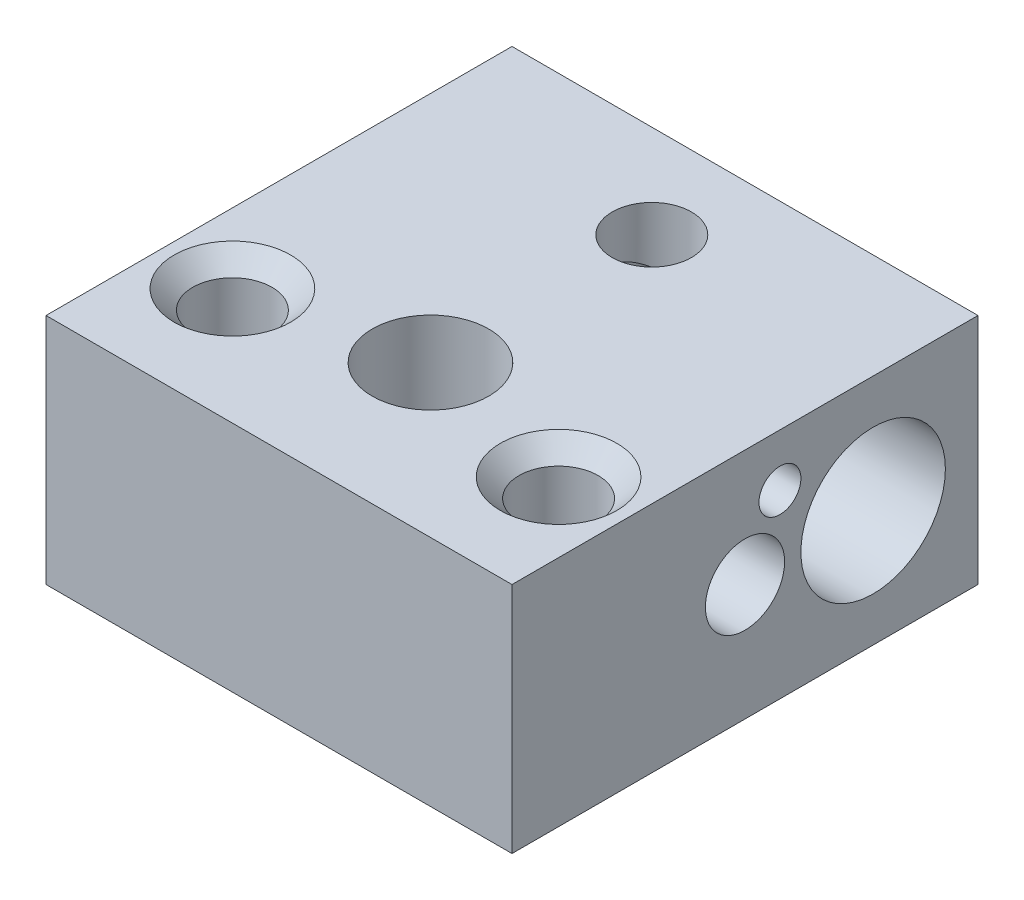
from build123d import *

# Parameters (mm, degrees)
CROQUIS1_W                                           = 20
CROQUIS1_H                                           = 20
SALIENTE_EXTRUIR1_DEPTH                              = 10
PERFORADOR_PARA_ROSCAR_PARA_MACHO_DE_ROS_D           = 5
REFRENTADO_PARA_TORNILLO_TAP_N_CON_CABEZ_D           = 3.4
REFRENTADO_PARA_TORNILLO_TAP_N_CON_CABEZ_CSINK_D     = 5
REFRENTADO_PARA_TORNILLO_TAP_N_CON_CABEZ_CSINK_ANGLE = 90
TALADRO_DE_MARGEN_PARA_M31_D                         = 3.4
CROQUIS17_R                                          = 3.1
CORTAR_EXTRUIR1_DEPTH                                = 20
TALADRO_DE_MARGEN_PARA_M32_D                         = 3.4
TALADRO_DE_MARGEN_PARA_M32_DEPTH                     = 7
CROQUIS21_R                                          = 0.9
CORTAR_EXTRUIR2_DEPTH                                = 2.75


with BuildPart() as part:
    # Croquis1 → Saliente-Extruir1 (new body)
    with BuildSketch(Plane(origin=(0, 0, 0), x_dir=(1, 0, 0), z_dir=(0, 1, 0))):
        Rectangle(CROQUIS1_W, CROQUIS1_H)
    extrude(amount=SALIENTE_EXTRUIR1_DEPTH)

    # Perforador para roscar para macho de roscar para M6x1.01 (through all)
    with Locations(Plane(origin=(0, 10, 0), x_dir=(1, 0, 0), z_dir=(0, 1, 0))):
        with Locations((0, -3.5)):
            Hole(PERFORADOR_PARA_ROSCAR_PARA_MACHO_DE_ROS_D / 2)

    # Refrentado para tornillo tapón con cabeza plana de clavija de M31 (through all)
    with Locations(Plane(origin=(0, 10, 0), x_dir=(1, 0, 0), z_dir=(0, 1, 0))):
        with Locations((-7, -5), (7, -5)):
            CounterSinkHole(REFRENTADO_PARA_TORNILLO_TAP_N_CON_CABEZ_D / 2, REFRENTADO_PARA_TORNILLO_TAP_N_CON_CABEZ_CSINK_D / 2, counter_sink_angle=REFRENTADO_PARA_TORNILLO_TAP_N_CON_CABEZ_CSINK_ANGLE)

    # Taladro de margen para M31 (through all)
    with Locations(Plane(origin=(0, 10, 0), x_dir=(1, 0, 0), z_dir=(0, 1, 0))):
        with Locations((0, 6)):
            Hole(TALADRO_DE_MARGEN_PARA_M31_D / 2)

    # Croquis17 → Cortar-Extruir1 (cut)
    with BuildSketch(Plane(origin=(10, 0, 0), x_dir=(0, 0, -1), z_dir=(1, 0, 0))):
        with Locations((5.5, 5)):
            Circle(CROQUIS17_R)
    extrude(amount=-CORTAR_EXTRUIR1_DEPTH, mode=Mode.SUBTRACT)

    # Taladro de margen para M32
    with Locations(Plane(origin=(10, 0, 0), x_dir=(0, 0, 1), z_dir=(1, 0, 0))):
        with Locations((0, -5)):
            Hole(TALADRO_DE_MARGEN_PARA_M32_D / 2, depth=TALADRO_DE_MARGEN_PARA_M32_DEPTH)

    # Croquis21 → Cortar-Extruir2 (cut)
    with BuildSketch(Plane.ZY.offset(-10)):
        with Locations((-1.5, 7.75)):
            Circle(CROQUIS21_R)
    extrude(amount=CORTAR_EXTRUIR2_DEPTH, mode=Mode.SUBTRACT)


solid = part.part
